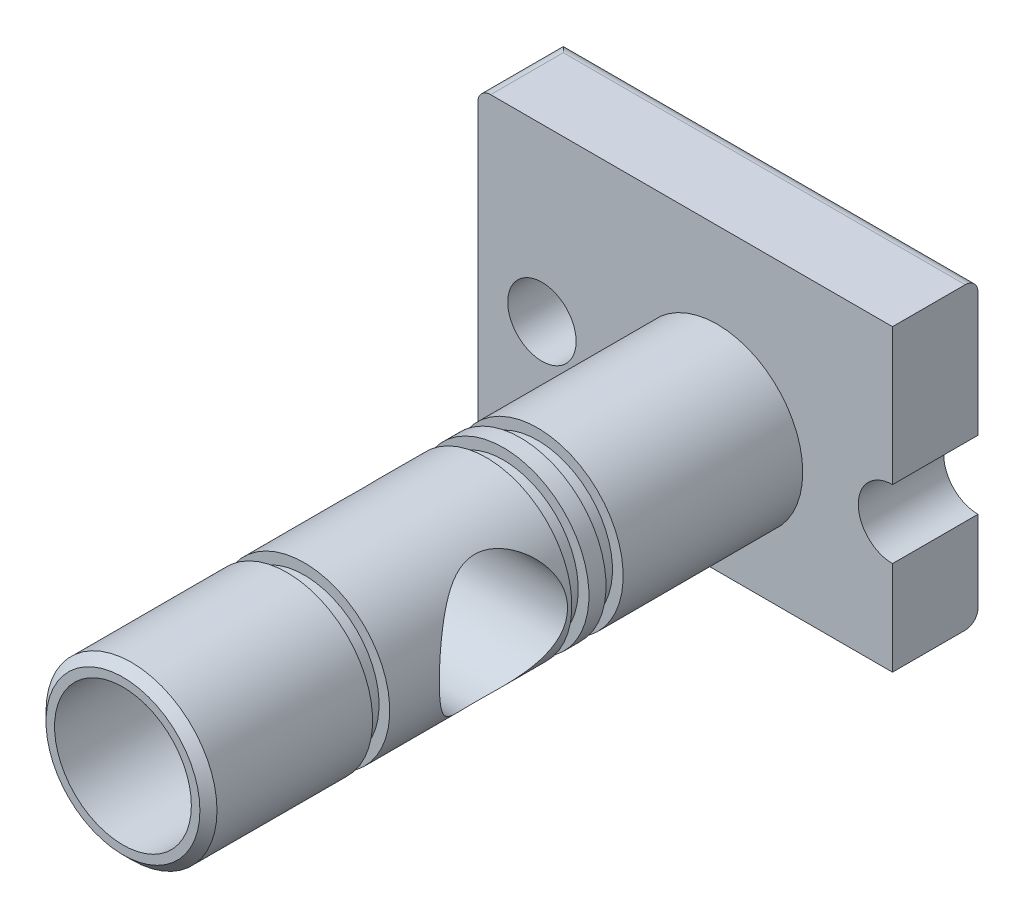
from build123d import *

# Parameters (mm, degrees)
SKETCH1_R               = 8
BOSS_EXTRUDE1_DEPTH     = 20
SKETCH2_R               = 20
BOSS_EXTRUDE2_DEPTH     = 139
SKETCH3_R               = 15
CUT_EXTRUDE1_DEPTH      = 42
CUT_EXTRUDE1_DEPTH_BACK = 57
SKETCH4_W               = 4
SKETCH4_H               = 2.5
SKETCH5_R               = 16
CUT_EXTRUDE2_DEPTH      = 35.4
SKETCH6_R               = 9.5
CUT_EXTRUDE3_DEPTH      = 22
CHAMFER1_SIZE           = 2
FILLET1_R               = 3


with BuildPart() as part:
    # Sketch1 → Boss-Extrude1 (new body)
    with BuildSketch(Plane.XY):
        with BuildLine():
            Line((-56, 40), (41, 40))
            Line((41, 40), (41, 8))
            ThreePointArc((41, 8), (33, 0), (41, -8))
            Line((41, -8), (41, -30))
            Line((41, -30), (-56, -30))
            Line((-56, -30), (-56, 40))
        make_face()
        with Locations((-41, 0)):
            Circle(SKETCH1_R, mode=Mode.SUBTRACT)
    extrude(amount=BOSS_EXTRUDE1_DEPTH)

    # Sketch2 → Boss-Extrude2 (add)
    with BuildSketch(Plane.XY.offset(20)):
        Circle(SKETCH2_R)
    extrude(amount=BOSS_EXTRUDE2_DEPTH)

    # Sketch3 → Cut-Extrude1 (cut, two sides)
    with BuildSketch(Plane(origin=(0, 0, 0), x_dir=(0, 0, -1), z_dir=(1, 0, 0))) as cut_extrude1_sk:
        with Locations((-90, 0)):
            Circle(SKETCH3_R)
    extrude(amount=CUT_EXTRUDE1_DEPTH, mode=Mode.SUBTRACT)
    extrude(cut_extrude1_sk.sketch, amount=-CUT_EXTRUDE1_DEPTH_BACK, mode=Mode.SUBTRACT)

    # Sketch4 → Cut-Revolve1 (revolve, cut)
    with BuildSketch(Plane(origin=(0, 0, 0), x_dir=(0, 0, -1), z_dir=(1, 0, 0))):
        with Locations((-64, 18.75)):
            Rectangle(SKETCH4_W, SKETCH4_H)
        with Locations((-72, 18.75)):
            Rectangle(SKETCH4_W, SKETCH4_H)
        with Locations((-118.6, 18.75)):
            Rectangle(SKETCH4_W, SKETCH4_H)
    revolve(axis=Axis((0, 0, 0), (0, 0, 1)), mode=Mode.SUBTRACT)

    # Sketch5 → Cut-Extrude2 (cut)
    with BuildSketch(Plane.XY.offset(159)):
        Circle(SKETCH5_R)
    extrude(amount=-CUT_EXTRUDE2_DEPTH, mode=Mode.SUBTRACT)

    # Sketch6 → Cut-Extrude3 (cut)
    with BuildSketch(Plane.XY.offset(123.6)):
        Circle(SKETCH6_R)
    extrude(amount=-CUT_EXTRUDE3_DEPTH, mode=Mode.SUBTRACT)

    # Chamfer1
    chamfer1_edges = [part.edges().sort_by_distance(p)[0] for p in [
        (-20, 0, 159),
    ]]
    chamfer(chamfer1_edges, length=CHAMFER1_SIZE)

    # Fillet1
    fillet1_edges = [part.edges().sort_by_distance(p)[0] for p in [
        (-56, 40, 10),
        (-56, -30, 10),
        (-7.5, 40, 0),
        (-7.5, -30, 0),
    ]]
    fillet(fillet1_edges, radius=FILLET1_R)


solid = part.part
